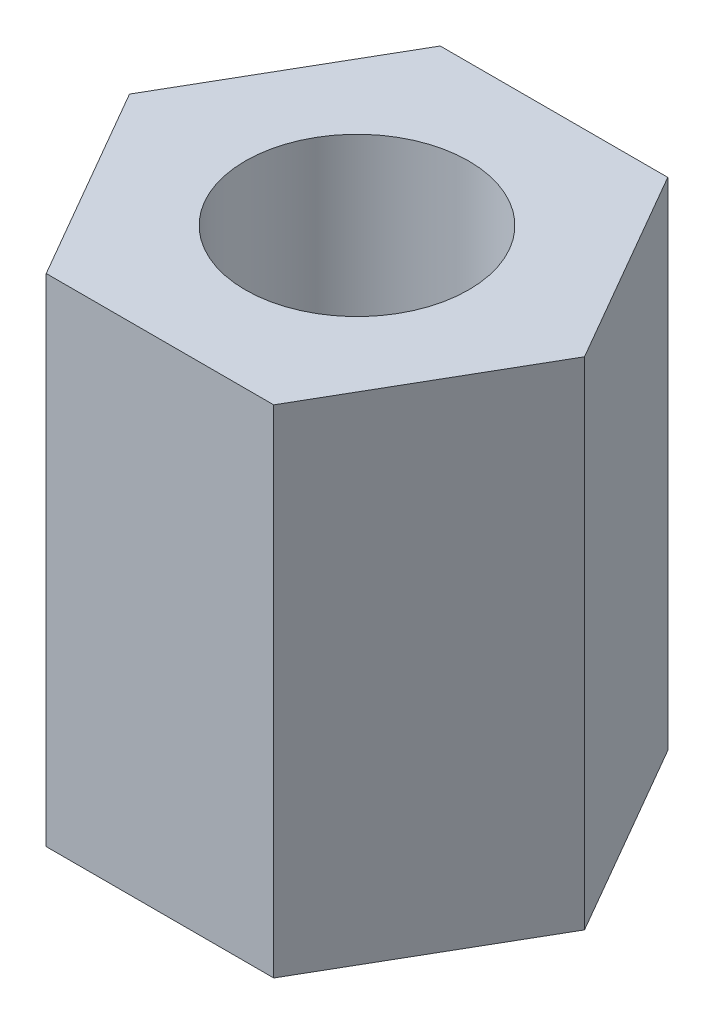
from build123d import *

# Parameters (mm, degrees)
SKETCH2_R           = 1.35
BOSS_EXTRUDE1_DEPTH = 6


with BuildPart() as part:
    # Sketch2 → Boss-Extrude1 (new body)
    with BuildSketch(Plane(origin=(0, 0, 0), x_dir=(1, 0, 0), z_dir=(0, 1, 0))):
        Polygon((2.75, 0), (1.375, 2.38156986), (-1.375, 2.38156986), (-2.75, 0), (-1.375, -2.38156986), (1.375, -2.38156986), align=None)
        Circle(SKETCH2_R, mode=Mode.SUBTRACT)
    extrude(amount=BOSS_EXTRUDE1_DEPTH)


solid = part.part
